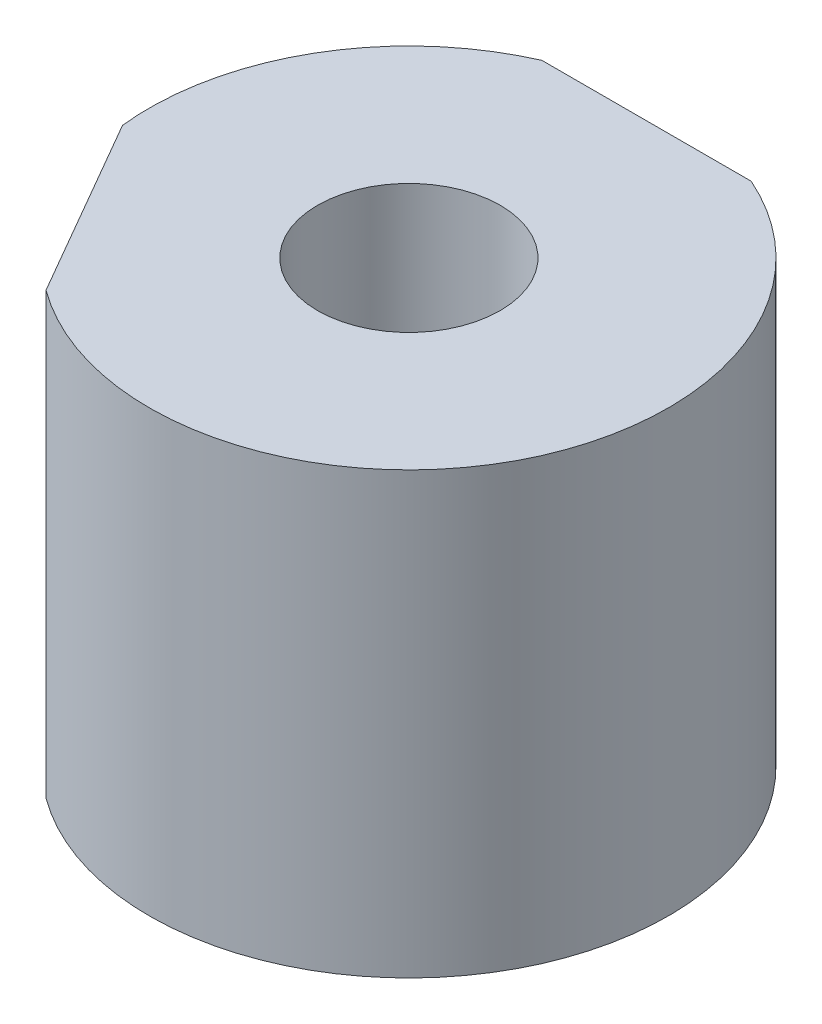
from build123d import *

# Parameters (mm, degrees)
SKETCH2_R           = 5.9
BOSS_EXTRUDE1_DEPTH = 10
SKETCH3_R           = 2.075
CUT_EXTRUDE1_DEPTH  = 11
SKETCH4_W           = 11.8
SKETCH4_H           = 1
CUT_EXTRUDE2_DEPTH  = 11
CIRPATTERN1_COUNT   = 2
CIRPATTERN1_ANGLE   = 120


with BuildPart() as part:
    # Sketch2 → Boss-Extrude1 (new body)
    with BuildSketch(Plane(origin=(0, 0, 0), x_dir=(1, 0, 0), z_dir=(0, 1, 0))):
        Circle(SKETCH2_R)
    extrude(amount=BOSS_EXTRUDE1_DEPTH)

    # Sketch3 → Cut-Extrude1 (cut, through all)
    with BuildSketch(Plane(origin=(0, 10, 0), x_dir=(1, 0, 0), z_dir=(0, 1, 0))):
        Circle(SKETCH3_R)
    extrude(amount=-CUT_EXTRUDE1_DEPTH, mode=Mode.SUBTRACT)

    # Sketch4 → Cut-Extrude2 (cut, through all)
    with BuildSketch(Plane(origin=(0, 10, 0), x_dir=(1, 0, 0), z_dir=(0, 1, 0))):
        with Locations((0, 5.9)):
            Rectangle(SKETCH4_W, SKETCH4_H)
    cut_extrude2 = extrude(amount=-CUT_EXTRUDE2_DEPTH, mode=Mode.SUBTRACT)

    # CirPattern1: Cut-Extrude2 ×2 about axis
    cirpattern1_axis = Axis((0, 10, 0), (0, 1, 0))
    for i in range(1, CIRPATTERN1_COUNT):
        add(cut_extrude2.rotate(cirpattern1_axis, i * CIRPATTERN1_ANGLE / (CIRPATTERN1_COUNT - 1)), mode=Mode.SUBTRACT)


solid = part.part
